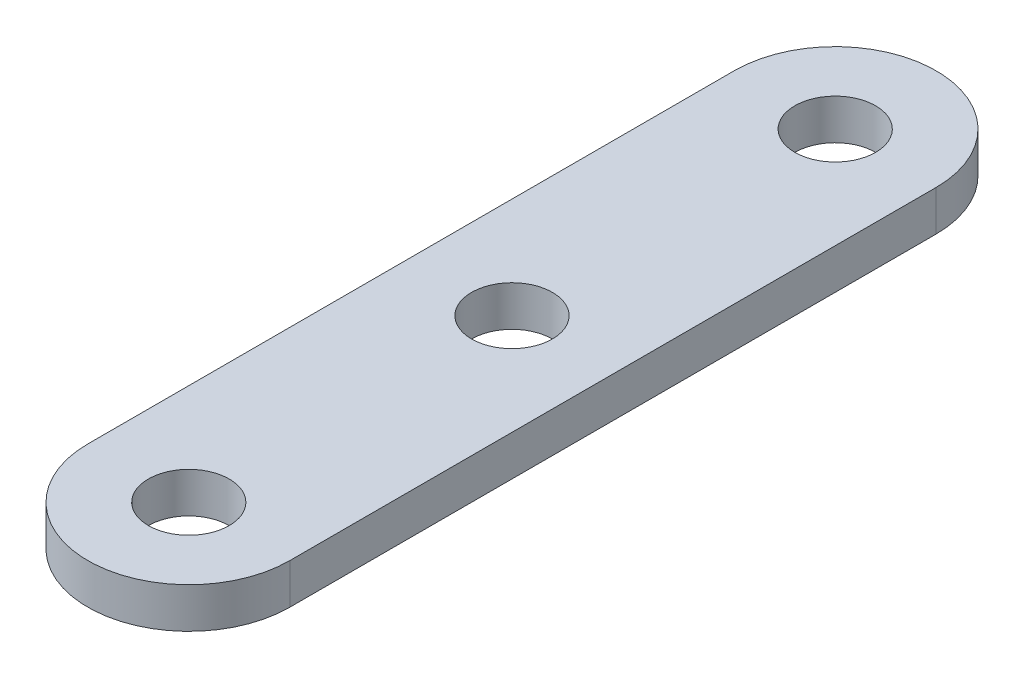
from build123d import *

# Parameters (mm, degrees)
SKETCH1_R           = 3.175
BOSS_EXTRUDE1_DEPTH = 3.175


with BuildPart() as part:
    # Sketch1 → Boss-Extrude1 (new body)
    with BuildSketch(Plane(origin=(0, 0, 0), x_dir=(1, 0, 0), z_dir=(0, 1, 0))):
        with BuildLine():
            ThreePointArc((7.9375, 50.8), (0, 58.7375), (-7.9375, 50.8))
            Line((-7.9375, 50.8), (-7.9375, 0))
            ThreePointArc((-7.9375, 0), (0, -7.9375), (7.9375, 0))
            Line((7.9375, 0), (7.9375, 50.8))
        make_face()
        with Locations((0, 50.8)):
            Circle(SKETCH1_R, mode=Mode.SUBTRACT)
        with Locations((0, 25.4)):
            Circle(SKETCH1_R, mode=Mode.SUBTRACT)
        Circle(SKETCH1_R, mode=Mode.SUBTRACT)
    extrude(amount=BOSS_EXTRUDE1_DEPTH)


solid = part.part
